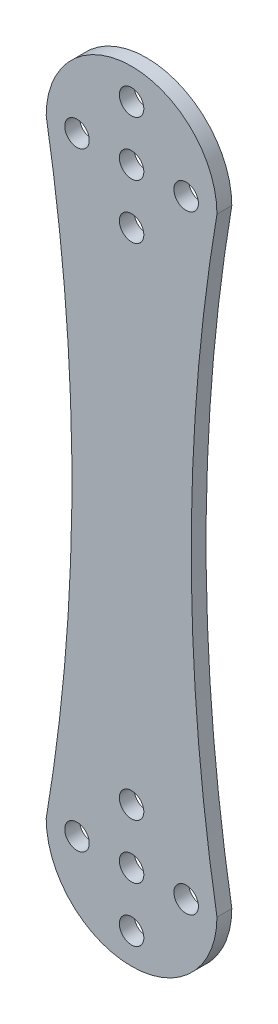
from build123d import *

# Parameters (mm, degrees)
SKETCH_1_R      = 1.65
EXTRUDE_2_DEPTH = 2


with BuildPart() as part:
    # 草图1 → 凸台-拉伸2 (new body)
    with BuildSketch(Plane.XY):
        with BuildLine():
            ThreePointArc((64.930621202, 11.618442311), (61.467079618, -29.381557689), (64.930621202, -70.381557689))
            ThreePointArc((64.930621202, -70.381557689), (53.430621202, -81.881557689), (41.930621202, -70.381557689))
            ThreePointArc((41.930621202, -70.381557689), (45.394162787, -29.381557689), (41.930621202, 11.618442311))
            ThreePointArc((41.930621202, 11.618442311), (53.430621202, 23.118442311), (64.930621202, 11.618442311))
        make_face()
        with Locations((46.080621202, -70.381557689)):
            Circle(SKETCH_1_R, mode=Mode.SUBTRACT)
        with Locations((53.430621202, 4.268442311)):
            Circle(SKETCH_1_R, mode=Mode.SUBTRACT)
        with Locations((53.430621202, 11.618442311)):
            Circle(SKETCH_1_R, mode=Mode.SUBTRACT)
        with Locations((46.080621202, 11.618442311)):
            Circle(SKETCH_1_R, mode=Mode.SUBTRACT)
        with Locations((53.430621202, 18.968442311)):
            Circle(SKETCH_1_R, mode=Mode.SUBTRACT)
        with Locations((60.780621202, 11.618442311)):
            Circle(SKETCH_1_R, mode=Mode.SUBTRACT)
        with Locations((53.430621202, -70.381557689)):
            Circle(SKETCH_1_R, mode=Mode.SUBTRACT)
        with Locations((53.430621202, -63.031557689)):
            Circle(SKETCH_1_R, mode=Mode.SUBTRACT)
        with Locations((60.780621202, -70.381557689)):
            Circle(SKETCH_1_R, mode=Mode.SUBTRACT)
        with Locations((53.430621202, -77.731557689)):
            Circle(SKETCH_1_R, mode=Mode.SUBTRACT)
    extrude(amount=EXTRUDE_2_DEPTH)


solid = part.part
